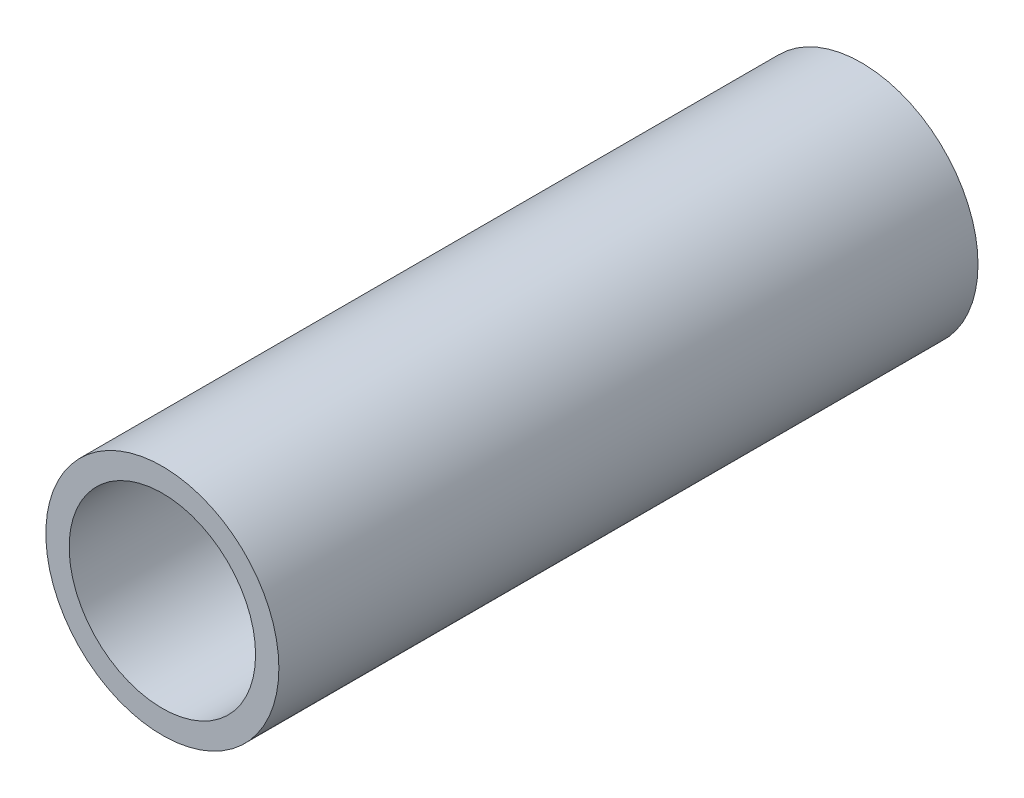
from build123d import *

# Parameters (mm, degrees)
SKETCH1_R           = 12.7
SKETCH1_R_2         = 10.16
BOSS_EXTRUDE1_DEPTH = 76.2


with BuildPart() as part:
    # Sketch1 → Boss-Extrude1 (new body)
    with BuildSketch(Plane.XY):
        Circle(SKETCH1_R)
        Circle(SKETCH1_R_2, mode=Mode.SUBTRACT)
    extrude(amount=BOSS_EXTRUDE1_DEPTH)


solid = part.part
